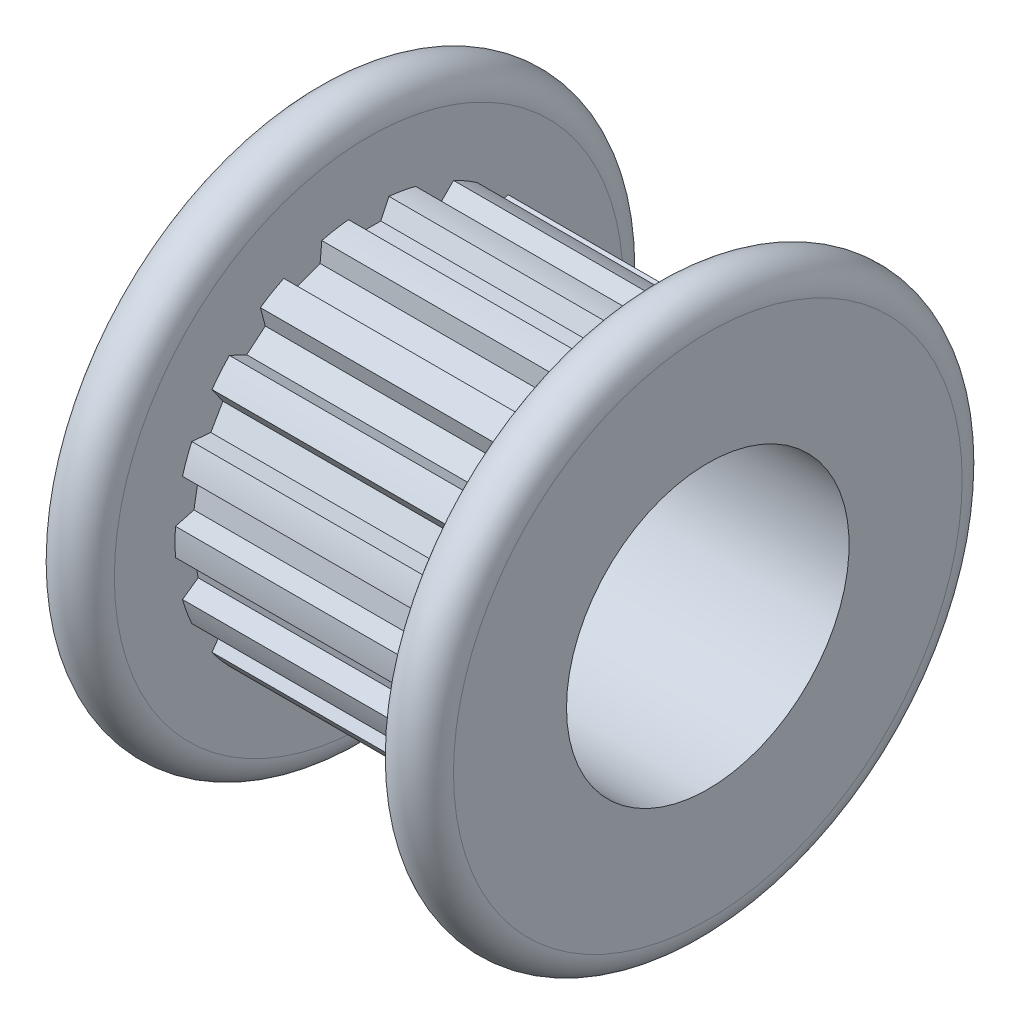
from build123d import *

# Parameters (mm, degrees)
SKETCH4_R          = 5.8
SKETCH4_R_2        = 5.4825
CUT_EXTRUDE2_DEPTH = 8
CUT_EXTRUDE1_DEPTH = 8
CIRPATTERN1_COUNT  = 18


with BuildPart() as part:
    # Sketch1 → Revolve1 (revolve)
    with BuildSketch(Plane.XY, mode=Mode.PRIVATE) as revolve1_sk:
        with BuildLine():
            Line((-1.6, 4), (9.6, 4))
            Line((9.6, 4), (9.6, 7.2))
            ThreePointArc((9.6, 7.2), (8.8, 8), (8, 7.2))
            Line((8, 7.2), (8, 5.55))
            Line((8, 5.55), (0, 5.55))
            Line((0, 5.55), (0, 7.2))
            ThreePointArc((0, 7.2), (-0.8, 8), (-1.6, 7.2))
            Line((-1.6, 7.2), (-1.6, 4))
        make_face()
    revolve(revolve1_sk.sketch.rotate(Axis((-1.6, 0, 0), (1, 0, 0)), 90), axis=Axis((-1.6, 0, 0), (1, 0, 0)))

    # Sketch4 → Cut-Extrude2 (cut)
    with BuildSketch(Plane(origin=(0, 0, 0), x_dir=(0, 0, -1), z_dir=(1, 0, 0))):
        Circle(SKETCH4_R)
        Circle(SKETCH4_R_2, mode=Mode.SUBTRACT)
    extrude(amount=CUT_EXTRUDE2_DEPTH, mode=Mode.SUBTRACT)

    # Sketch3 → Cut-Extrude1 (cut)
    with BuildSketch(Plane(origin=(0, 0, 0), x_dir=(0, 0, -1), z_dir=(1, 0, 0))):
        with BuildLine():
            Line((-0.642345316, 5.604560113), (-0.343021997, 4.962659182))
            Line((-0.343021997, 4.962659182), (0.343021997, 4.962659182))
            Line((0.343021997, 4.962659182), (0.642345316, 5.604560113))
            ThreePointArc((0.642345316, 5.604560113), (0, 5.64125), (-0.642345316, 5.604560113))
        make_face()
    cut_extrude1 = extrude(amount=CUT_EXTRUDE1_DEPTH, mode=Mode.SUBTRACT)

    # CirPattern1: Cut-Extrude1 ×18 about axis
    cirpattern1_axis = Axis((0, 0, 0), (1, 0, 0))
    for i in range(1, CIRPATTERN1_COUNT):
        add(cut_extrude1.rotate(cirpattern1_axis, i * 360 / CIRPATTERN1_COUNT), mode=Mode.SUBTRACT)


solid = part.part
